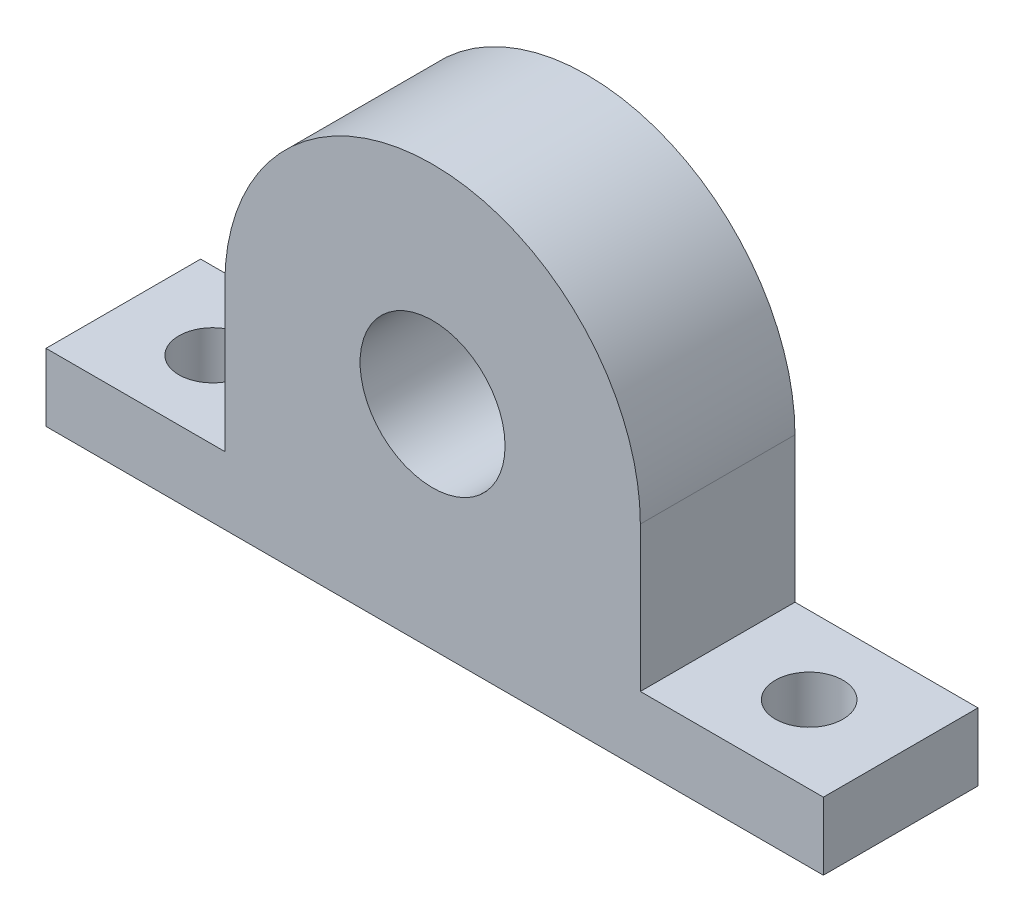
from build123d import *

# Parameters (mm, degrees)
SKETCH_1_R          = 7.5
EXTRUDE_2_DEPTH     = 16
SKETCH_2_R          = 3.5
CUT_EXTRUDE_1_DEPTH = 16


with BuildPart() as part:
    # 草图1 → 凸台-拉伸2 (new body)
    with BuildSketch(Plane.XY):
        with BuildLine():
            Line((15.402921801, -15), (21.5, -15))
            Line((21.5, -15), (21.5, 0))
            ThreePointArc((21.5, 0), (19.917490037, -8.095899619), (15.402921801, -15))
        make_face()
        with BuildLine():
            ThreePointArc((21.5, 0), (0, 21.5), (-21.5, 0))
            ThreePointArc((-21.5, 0), (-19.917490037, -8.095899619), (-15.402921801, -15))
            Line((-15.402921801, -15), (15.402921801, -15))
            ThreePointArc((15.402921801, -15), (19.917490037, -8.095899619), (21.5, 0))
        make_face()
        Circle(SKETCH_1_R, mode=Mode.SUBTRACT)
        with BuildLine():
            Line((-21.5, 0), (-21.5, -15))
            Line((-21.5, -15), (-15.402921801, -15))
            ThreePointArc((-15.402921801, -15), (-19.917490037, -8.095899619), (-21.5, 0))
        make_face()
        with BuildLine():
            Line((-40, -22), (0, -22))
            Line((0, -22), (40, -22))
            Line((40, -22), (40.439940075, -22))
            Line((40.439940075, -22), (40.439940075, -15))
            Line((40.439940075, -15), (21.5, -15))
            Line((21.5, -15), (15.402921801, -15))
            ThreePointArc((15.402921801, -15), (0, -21.5), (-15.402921801, -15))
            Line((-15.402921801, -15), (-21.5, -15))
            Line((-21.5, -15), (-40, -15))
            Line((-40, -15), (-40, -22))
        make_face()
        with BuildLine():
            Line((15.402921801, -15), (-15.402921801, -15))
            ThreePointArc((-15.402921801, -15), (0, -21.5), (15.402921801, -15))
        make_face()
    extrude(amount=EXTRUDE_2_DEPTH)

    # 草图2 → 切除-拉伸1 (cut)
    with BuildSketch(Plane(origin=(0, -15, 0), x_dir=(1, 0, 0), z_dir=(0, 1, 0))):
        with Locations((-30.75, -8)):
            Circle(SKETCH_2_R)
        with Locations((30.969970037, -8)):
            Circle(SKETCH_2_R)
    extrude(amount=-CUT_EXTRUDE_1_DEPTH, mode=Mode.SUBTRACT)


solid = part.part
